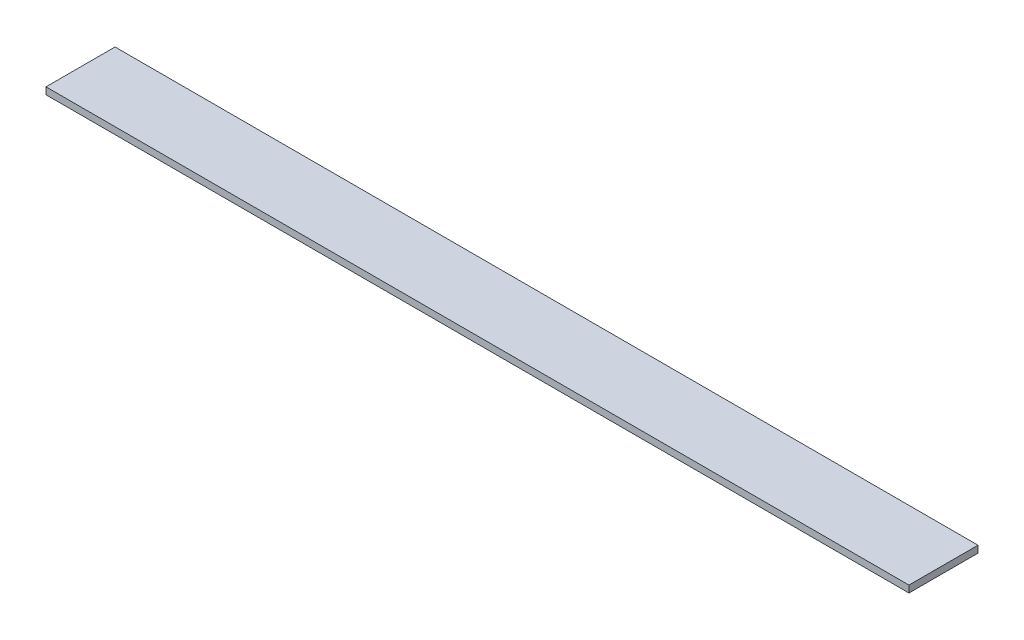
from build123d import *

# Parameters (mm, degrees)
SKETCH1_W           = 1250
SKETCH1_H           = 100
BOSS_EXTRUDE1_DEPTH = 10


with BuildPart() as part:
    # Sketch1 → Boss-Extrude1 (new body)
    with BuildSketch(Plane(origin=(0, 0, 0), x_dir=(1, 0, 0), z_dir=(0, 1, 0))):
        Rectangle(SKETCH1_W, SKETCH1_H)
    extrude(amount=BOSS_EXTRUDE1_DEPTH)


solid = part.part
